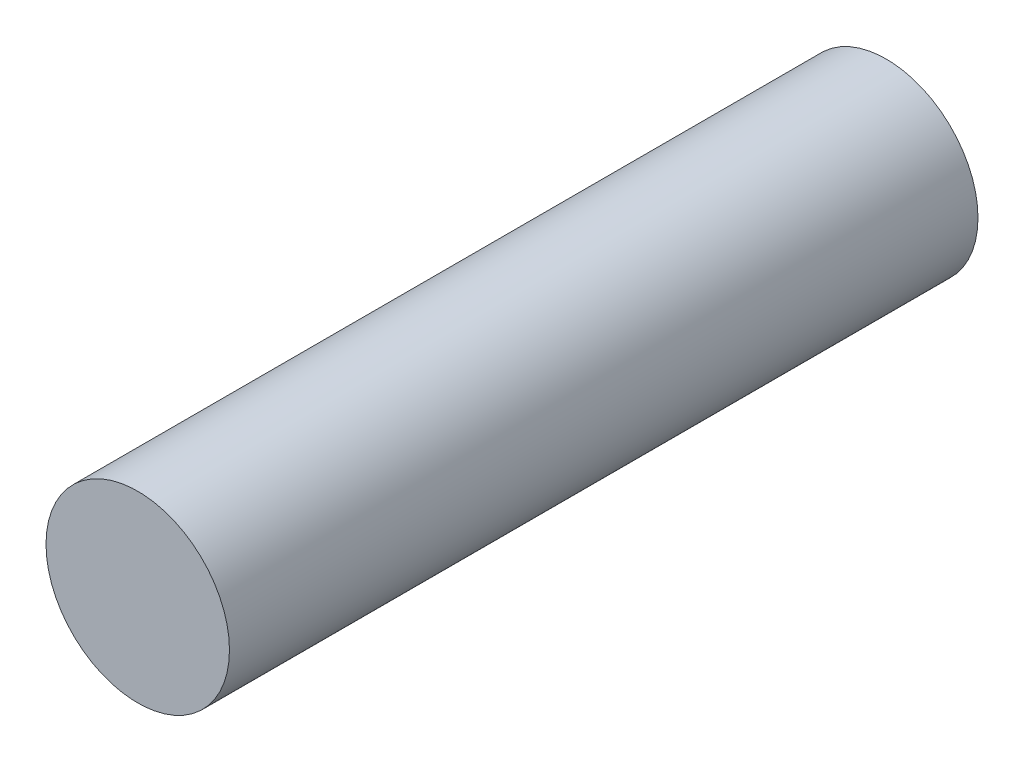
from build123d import *

# Parameters (mm, degrees)
SKETCH1_R           = 5
BOSS_EXTRUDE1_DEPTH = 40.8


with BuildPart() as part:
    # Sketch1 → Boss-Extrude1 (new body)
    with BuildSketch(Plane.XY):
        Circle(SKETCH1_R)
    extrude(amount=BOSS_EXTRUDE1_DEPTH)


solid = part.part
